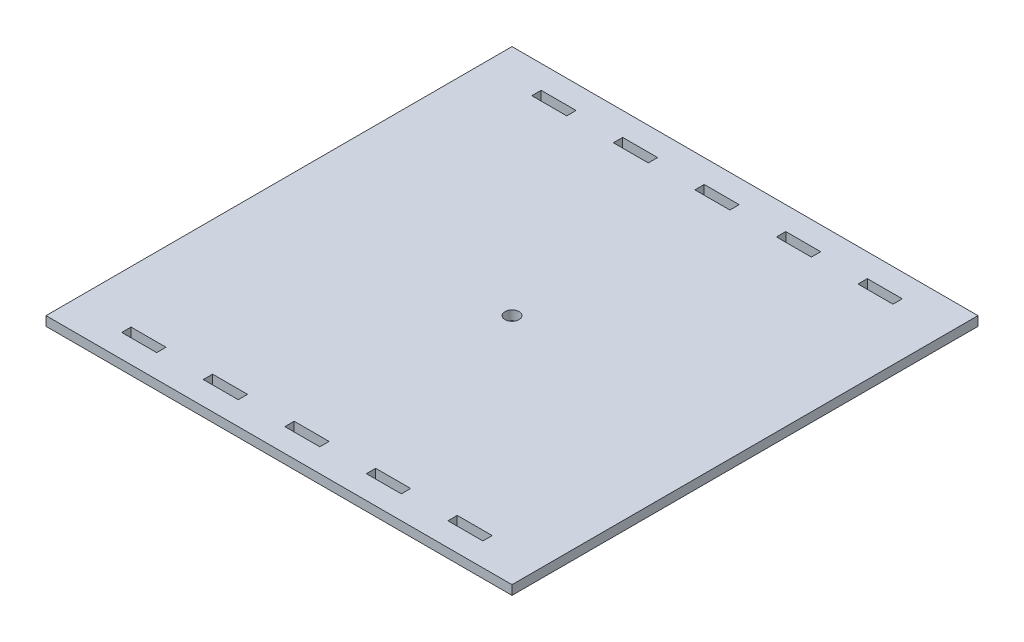
from build123d import *

# Parameters (mm, degrees)
SKETCH1_W           = 200
SKETCH1_H           = 200
SKETCH1_R           = 3
SKETCH1_W_2         = 15
SKETCH1_H_2         = 4
BOSS_EXTRUDE1_DEPTH = 4


with BuildPart() as part:
    # Sketch1 → Boss-Extrude1 (new body)
    with BuildSketch(Plane(origin=(0, 0, 0), x_dir=(1, 0, 0), z_dir=(0, 1, 0))):
        with Locations((100, -100)):
            Rectangle(SKETCH1_W, SKETCH1_H)
        with Locations((100, -100)):
            Circle(SKETCH1_R, mode=Mode.SUBTRACT)
        with Locations((30, -12)):
            Rectangle(SKETCH1_W_2, SKETCH1_H_2, mode=Mode.SUBTRACT)
        with Locations((65, -12)):
            Rectangle(SKETCH1_W_2, SKETCH1_H_2, mode=Mode.SUBTRACT)
        with Locations((100, -12)):
            Rectangle(SKETCH1_W_2, SKETCH1_H_2, mode=Mode.SUBTRACT)
        with Locations((135, -12)):
            Rectangle(SKETCH1_W_2, SKETCH1_H_2, mode=Mode.SUBTRACT)
        with Locations((170, -12)):
            Rectangle(SKETCH1_W_2, SKETCH1_H_2, mode=Mode.SUBTRACT)
        with Locations((170, -188)):
            Rectangle(SKETCH1_W_2, SKETCH1_H_2, mode=Mode.SUBTRACT)
        with Locations((135, -188)):
            Rectangle(SKETCH1_W_2, SKETCH1_H_2, mode=Mode.SUBTRACT)
        with Locations((100, -188)):
            Rectangle(SKETCH1_W_2, SKETCH1_H_2, mode=Mode.SUBTRACT)
        with Locations((65, -188)):
            Rectangle(SKETCH1_W_2, SKETCH1_H_2, mode=Mode.SUBTRACT)
        with Locations((30, -188)):
            Rectangle(SKETCH1_W_2, SKETCH1_H_2, mode=Mode.SUBTRACT)
    extrude(amount=BOSS_EXTRUDE1_DEPTH)


solid = part.part
